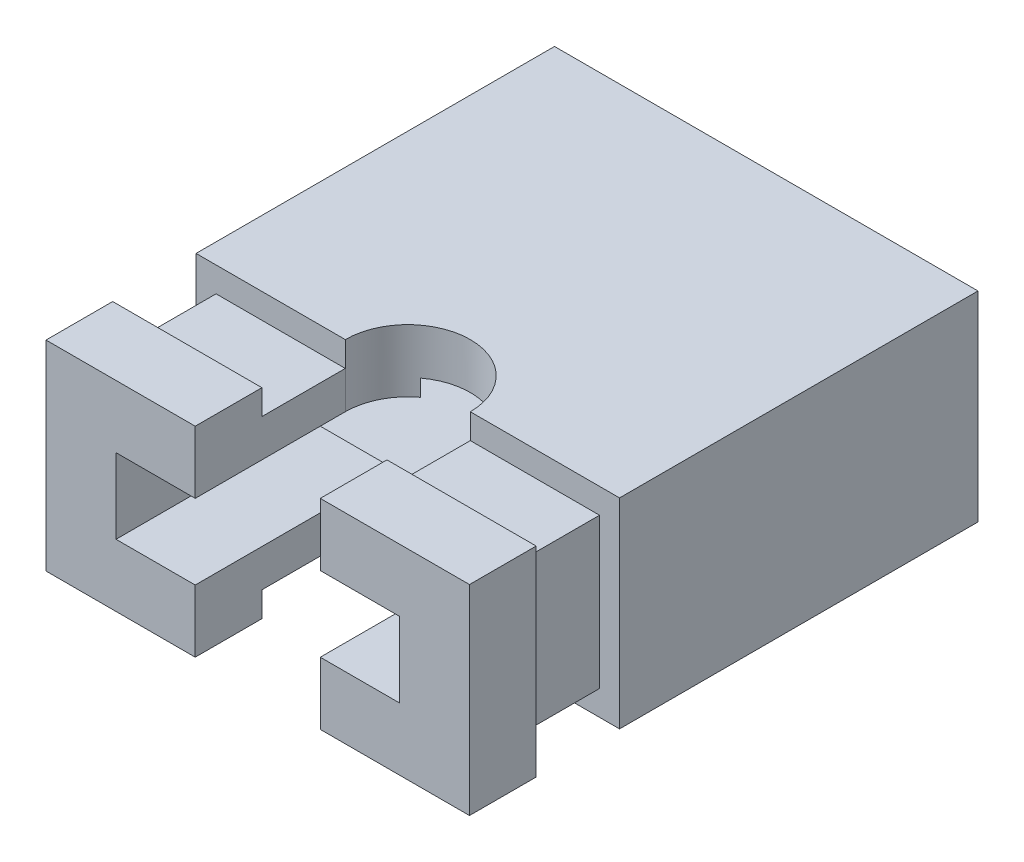
from build123d import *

# Parameters (mm, degrees)
SKETCH1_W             = 5.08
SKETCH1_H             = 2.4
EXTRUDE_223_DEPTH     = 4.3
SKETCH2_W             = 4.6
SKETCH2_H             = 1.8
EXTRUDE_304_DEPTH     = 1
SKETCH3_W             = 5.08
SKETCH3_H             = 2.4
EXTRUDE_441_DEPTH     = 0.8
SKETCH4_W             = 3.8
SKETCH4_H             = 1.3
CUT_EXTRUDE_523_DEPTH = 3.7
SKETCH5_W             = 3.4
SKETCH5_H             = 0.9
CUT_EXTRUDE_605_DEPTH = 5
CUT_EXTRUDE_729_DEPTH = 3


with BuildPart() as part:
    # Sketch1 → Extrude 223 (new body)
    with BuildSketch(Plane.XY):
        Rectangle(SKETCH1_W, SKETCH1_H)
    extrude(amount=EXTRUDE_223_DEPTH)

    # Sketch2 → Extrude 304 (add)
    with BuildSketch(Plane.XY.offset(4.3)):
        Rectangle(SKETCH2_W, SKETCH2_H)
    extrude(amount=EXTRUDE_304_DEPTH)

    # Sketch3 → Extrude 441 (add)
    with BuildSketch(Plane.XY.offset(5.3)):
        Rectangle(SKETCH3_W, SKETCH3_H)
    extrude(amount=EXTRUDE_441_DEPTH)

    # Sketch4 → Cut-Extrude 523 (cut)
    with BuildSketch(Plane(origin=(0, 0, 0), x_dir=(-1, 0, 0), z_dir=(0, 0, -1))):
        Rectangle(SKETCH4_W, SKETCH4_H)
    extrude(amount=-CUT_EXTRUDE_523_DEPTH, mode=Mode.SUBTRACT)

    # Sketch5 → Cut-Extrude 605 (cut)
    with BuildSketch(Plane(origin=(0, 0, 3.7), x_dir=(-1, 0, 0), z_dir=(0, 0, -1))):
        Rectangle(SKETCH5_W, SKETCH5_H)
    extrude(amount=-CUT_EXTRUDE_605_DEPTH, mode=Mode.SUBTRACT)

    # Sketch7 → Cut-Extrude 729 (cut)
    with BuildSketch(Plane.XZ.offset(1.2)):
        with BuildLine():
            Line((-0.75, 6.1), (-0.75, 4.3))
            ThreePointArc((-0.75, 4.3), (0, 3.55), (0.75, 4.3))
            Line((0.75, 4.3), (0.75, 6.1))
            Line((0.75, 6.1), (-0.75, 6.1))
        make_face()
    extrude(amount=-CUT_EXTRUDE_729_DEPTH, mode=Mode.SUBTRACT)


solid = part.part
